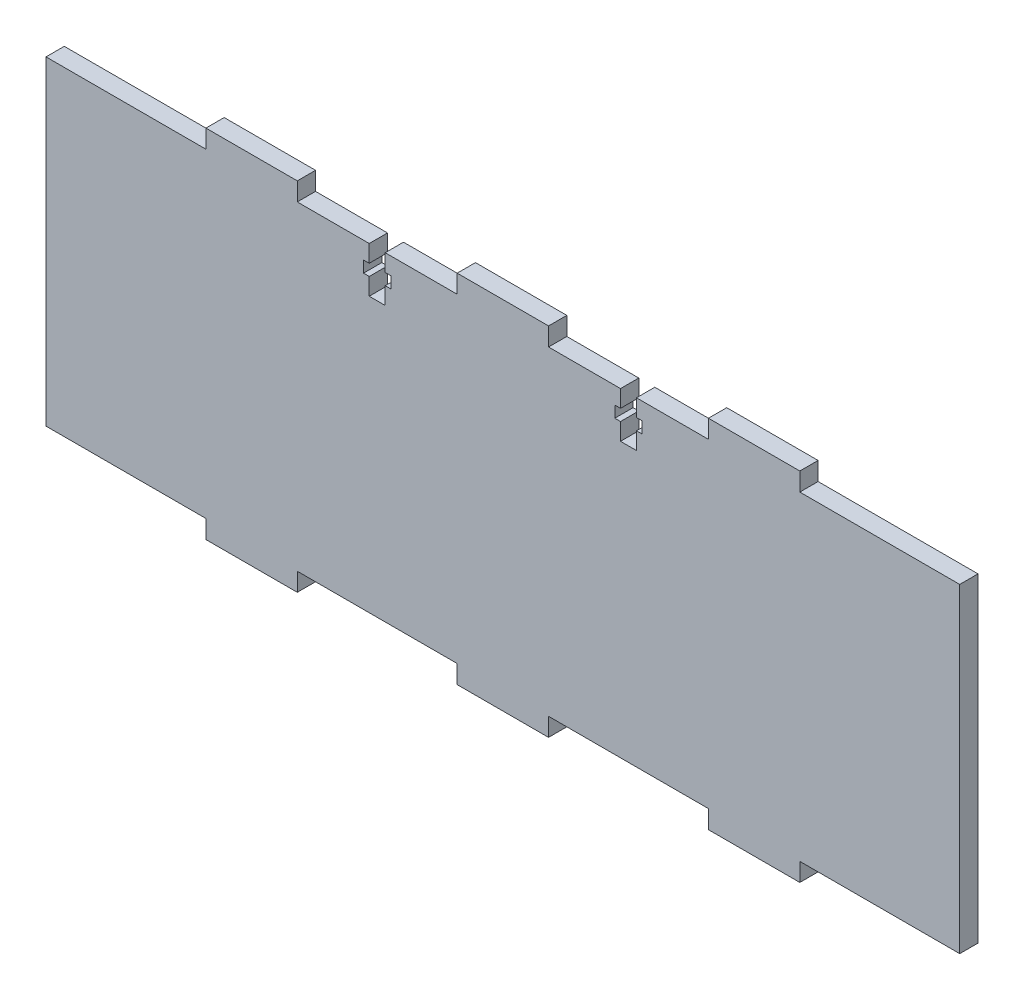
from build123d import *

# Parameters (mm, degrees)
SKETCH1_W           = 200
SKETCH1_H           = 78
BOSS_EXTRUDE1_DEPTH = 4
SKETCH2_W           = 35
SKETCH2_H           = 4
CUT_EXTRUDE1_DEPTH  = 4
SKETCH4_W           = 3.5
SKETCH4_H           = 2
SKETCH4_H_2         = 4
CUT_EXTRUDE4_DEPTH  = 10
SKETCH5_W           = 6
SKETCH5_H           = 2.5
CUT_EXTRUDE5_DEPTH  = 4


with BuildPart() as part:
    # Sketch1 → Boss-Extrude1 (new body)
    with BuildSketch(Plane.XY):
        with Locations((-100, 39)):
            Rectangle(SKETCH1_W, SKETCH1_H)
    extrude(amount=BOSS_EXTRUDE1_DEPTH)

    # Sketch2 → Cut-Extrude1 (cut)
    with BuildSketch(Plane.XY.offset(4)):
        with Locations((-182.5, 76)):
            Rectangle(SKETCH2_W, SKETCH2_H)
        with Locations((-127.5, 76)):
            Rectangle(SKETCH2_W, SKETCH2_H)
        with Locations((-72.5, 76)):
            Rectangle(SKETCH2_W, SKETCH2_H)
        with Locations((-17.5, 76)):
            Rectangle(SKETCH2_W, SKETCH2_H)
        with Locations((-182.5, 2)):
            Rectangle(SKETCH2_W, SKETCH2_H)
        with Locations((-127.5, 2)):
            Rectangle(SKETCH2_W, SKETCH2_H)
        with Locations((-72.5, 2)):
            Rectangle(SKETCH2_W, SKETCH2_H)
        with Locations((-17.5, 2)):
            Rectangle(SKETCH2_W, SKETCH2_H)
    extrude(amount=-CUT_EXTRUDE1_DEPTH, mode=Mode.SUBTRACT)

    # Sketch4 → Cut-Extrude4 (cut)
    with BuildSketch(Plane(origin=(0, 74, 0), x_dir=(1, 0, 0), z_dir=(0, 1, 0))):
        with Locations((-127.5, -3)):
            Rectangle(SKETCH4_W, SKETCH4_H)
        with Locations((-127.5, -1)):
            Rectangle(SKETCH4_W, SKETCH4_H)
        with Locations((-72.5, -2)):
            Rectangle(SKETCH4_W, SKETCH4_H_2)
    extrude(amount=-CUT_EXTRUDE4_DEPTH, mode=Mode.SUBTRACT)

    # Sketch5 → Cut-Extrude5 (cut)
    with BuildSketch(Plane(origin=(0, 0, 0), x_dir=(-1, 0, 0), z_dir=(0, 0, -1))):
        with Locations((127.5, 69)):
            Rectangle(SKETCH5_W, SKETCH5_H)
        with Locations((72.5, 69)):
            Rectangle(SKETCH5_W, SKETCH5_H)
    extrude(amount=-CUT_EXTRUDE5_DEPTH, mode=Mode.SUBTRACT)


solid = part.part
